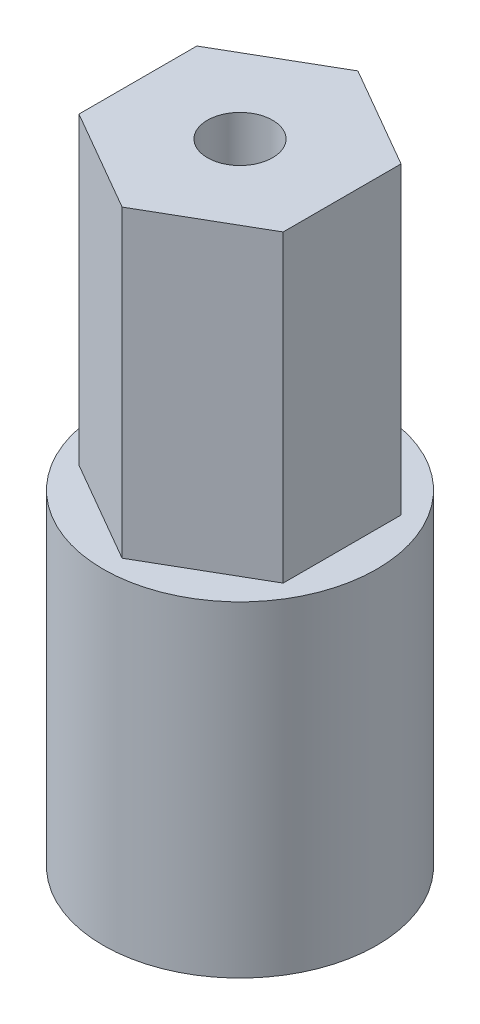
from build123d import *

# Parameters (mm, degrees)
SKETCH1_R           = 8.001
BOSS_EXTRUDE1_DEPTH = 6.35
SKETCH3_R           = 8.001
BOSS_EXTRUDE2_DEPTH = 12.7
CUT_EXTRUDE1_DEPTH  = 12.7
SKETCH11_R          = 1.905
BOSS_EXTRUDE5_DEPTH = 17.78


with BuildPart() as part:
    # Sketch1 → Boss-Extrude1 (new body)
    with BuildSketch(Plane(origin=(0, 0, 0), x_dir=(1, 0, 0), z_dir=(0, 1, 0))):
        Circle(SKETCH1_R)
    extrude(amount=BOSS_EXTRUDE1_DEPTH)

    # Sketch3 → Boss-Extrude2 (add)
    with BuildSketch(Plane(origin=(0, 0, 0), x_dir=(-1, 0, 0), z_dir=(0, -1, 0))):
        Circle(SKETCH3_R)
    extrude(amount=BOSS_EXTRUDE2_DEPTH)

    # Sketch4 → Cut-Extrude1 (cut)
    with BuildSketch(Plane.XZ.offset(12.7)):
        Polygon((8.54e-07, 2.793990901), (-1.975654462, 4.769648278), (-4.769655316, 1.975649132), (-2.794, -8.246e-06), (-4.769655493, -1.975665446), (-1.97565137, -4.769661323), (0, -2.794), (1.975656347, -4.769656347), (4.769656347, -1.975656347), (2.794, 0), (4.76965137, 1.975661323), (1.975647247, 4.7696572), align=None)
    extrude(amount=-CUT_EXTRUDE1_DEPTH, mode=Mode.SUBTRACT)

    # Sketch11 → Boss-Extrude5 (add)
    with BuildSketch(Plane(origin=(0, 6.35, 0), x_dir=(1, 0, 0), z_dir=(0, 1, 0))):
        Polygon((0, 6.892407514), (-5.969, 3.446203757), (-5.969, -3.446203757), (0, -6.892407514), (5.969, -3.446203757), (5.969, 3.446203757), align=None)
        Circle(SKETCH11_R, mode=Mode.SUBTRACT)
    extrude(amount=BOSS_EXTRUDE5_DEPTH)


solid = part.part
